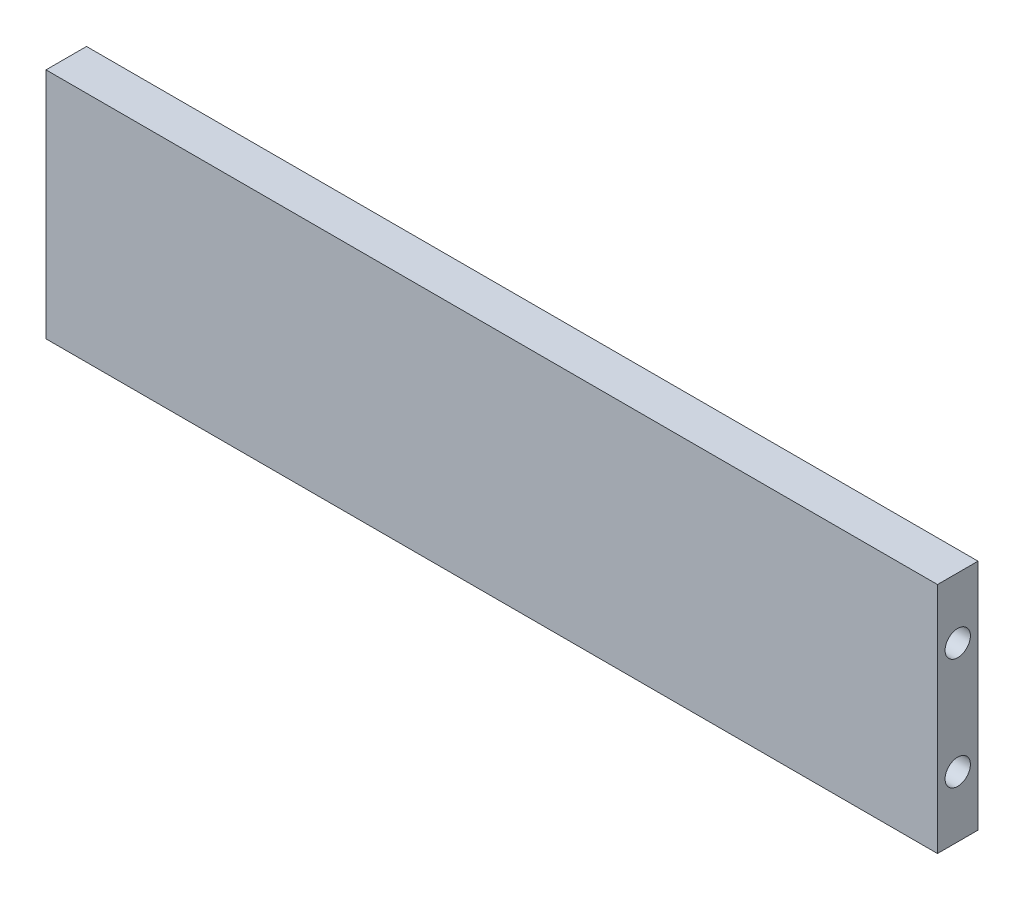
from build123d import *

# Parameters (mm, degrees)
ESBO_O1_W                = 88.01
ESBO_O1_H                = 23
RESSALTO_EXTRUS_O1_DEPTH = 4
ESBO_O2_R                = 1.25
CORTE_EXTRUS_O1_DEPTH    = 10
ESBO_O3_R                = 1.25
CORTE_EXTRUS_O2_DEPTH    = 10


with BuildPart() as part:
    # Esboço1 → Ressalto-extrusão1 (new body)
    with BuildSketch(Plane.XY):
        with Locations((44.005, -11.5)):
            Rectangle(ESBO_O1_W, ESBO_O1_H)
    extrude(amount=RESSALTO_EXTRUS_O1_DEPTH)

    # Esboço2 → Corte-extrusão1 (cut)
    with BuildSketch(Plane.ZY):
        with Locations((2, -6)):
            Circle(ESBO_O2_R)
        with Locations((2, -17)):
            Circle(ESBO_O2_R)
    extrude(amount=-CORTE_EXTRUS_O1_DEPTH, mode=Mode.SUBTRACT)

    # Esboço3 → Corte-extrusão2 (cut)
    with BuildSketch(Plane(origin=(88.01, 0, 0), x_dir=(0, 0, -1), z_dir=(1, 0, 0))):
        with Locations((-2, -6)):
            Circle(ESBO_O3_R)
        with Locations((-2, -17)):
            Circle(ESBO_O3_R)
    extrude(amount=-CORTE_EXTRUS_O2_DEPTH, mode=Mode.SUBTRACT)


solid = part.part
